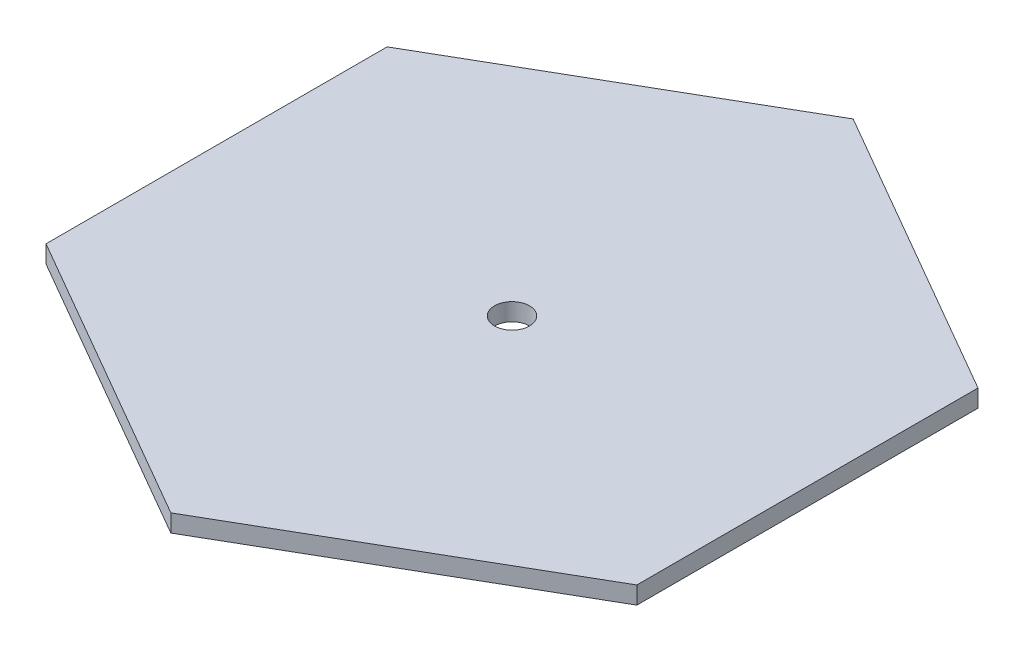
from build123d import *

# Parameters (mm, degrees)
BOSS_EXTRUDE1_DEPTH = 2
CUT_EXTRUDE1_REACH  = 4
SKETCH2_R           = 2


with BuildPart() as part:
    # Sketch1 → Boss-Extrude1 (new body)
    with BuildSketch(Plane(origin=(0, 0, 0), x_dir=(1, 0, 0), z_dir=(0, 1, 0))):
        Polygon((33.774990748, 19.5), (0, 39), (-33.774990748, 19.5), (-33.774990748, -19.5), (0, -39), (33.774990748, -19.5), align=None)
    extrude(amount=BOSS_EXTRUDE1_DEPTH)

    # Sketch2 → Cut-Extrude1 (cut, up to next)
    with BuildSketch(Plane(origin=(0, 2, 0), x_dir=(1, 0, 0), z_dir=(0, 1, 0)), mode=Mode.PRIVATE) as cut_extrude1_sk1:
        Circle(SKETCH2_R)
    cut_extrude1_tool1 = extrude(cut_extrude1_sk1.sketch, amount=-CUT_EXTRUDE1_REACH, mode=Mode.PRIVATE) & part.part
    add(cut_extrude1_tool1.solids().sort_by_distance((0, 2, 0))[0], mode=Mode.SUBTRACT)


solid = part.part
